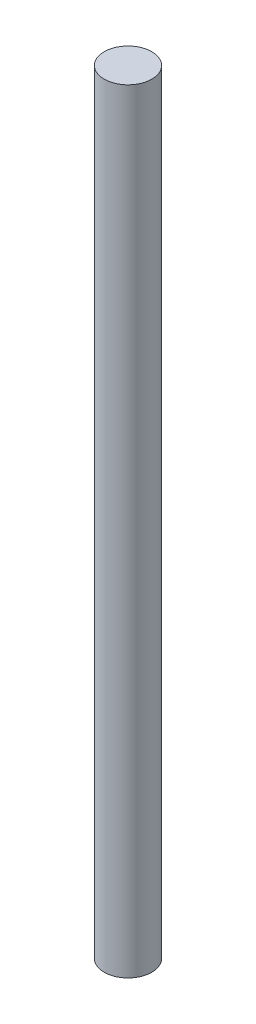
from build123d import *

# Parameters (mm, degrees)
SKETCH1_W = 2
SKETCH1_H = 65


with BuildPart() as part:
    # Sketch1 → Revolve1 (revolve)
    with BuildSketch(Plane.XY):
        with Locations((1, 0)):
            Rectangle(SKETCH1_W, SKETCH1_H)
    revolve(axis=Axis((0, 0, 0), (0, 1, 0)))


solid = part.part
